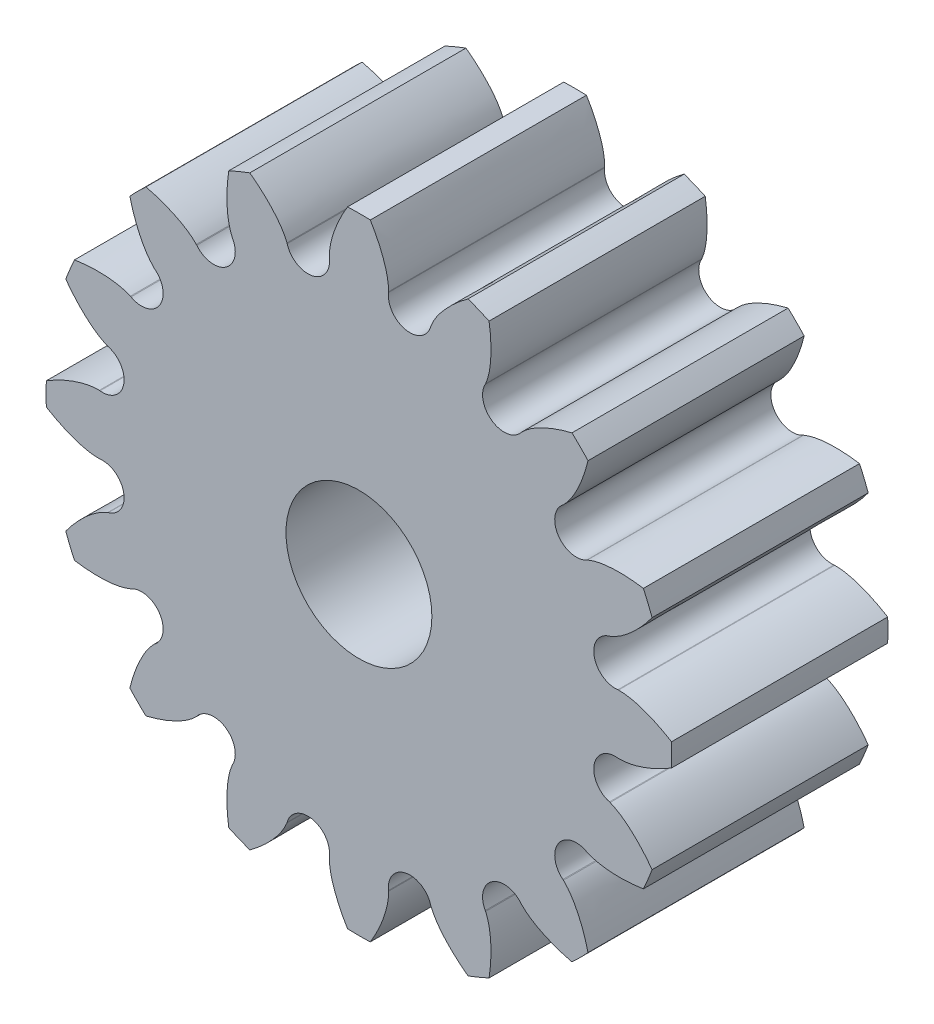
from build123d import *

# Parameters (mm, degrees)
SKETCH3_R                      = 3.3401
SKETCH3_R_2                    = 1.016
BASE_DEPTH                     = 3.0099
HALF_TOOTH_DEPTH               = 3.0099
PATTERN_OF_TOOTH_COUNT         = 16
PATTERN_OF_TOOTH_COPY_1_DEPTH  = 3.0099
PATTERN_OF_TOOTH_COPY_2_DEPTH  = 3.0099
PATTERN_OF_TOOTH_COPY_3_DEPTH  = 3.0099
PATTERN_OF_TOOTH_COPY_4_DEPTH  = 3.0099
PATTERN_OF_TOOTH_COPY_5_DEPTH  = 3.0099
PATTERN_OF_TOOTH_COPY_6_DEPTH  = 3.0099
PATTERN_OF_TOOTH_COPY_7_DEPTH  = 3.0099
PATTERN_OF_TOOTH_COPY_8_DEPTH  = 3.0099
PATTERN_OF_TOOTH_COPY_9_DEPTH  = 3.0099
PATTERN_OF_TOOTH_COPY_10_DEPTH = 3.0099
PATTERN_OF_TOOTH_COPY_11_DEPTH = 3.0099
PATTERN_OF_TOOTH_COPY_12_DEPTH = 3.0099
PATTERN_OF_TOOTH_COPY_13_DEPTH = 3.0099
PATTERN_OF_TOOTH_COPY_14_DEPTH = 3.0099
PATTERN_OF_TOOTH_COPY_15_DEPTH = 3.0099


with BuildPart() as part:
    # Sketch3 → Base (new body)
    with BuildSketch(Plane.XY):
        Circle(SKETCH3_R)
        Circle(SKETCH3_R_2, mode=Mode.SUBTRACT)
    extrude(amount=BASE_DEPTH)

    # Sketch2 → Half tooth (add)
    with BuildSketch(Plane.XY):
        with BuildLine():
            Line((0, 4.3561), (0, 3.3401))
            ThreePointArc((0, 3.3401), (0.32738705, 3.324016506), (0.651621185, 3.275920915))
            ThreePointArc((0.651621185, 3.275920915), (0.467325041, 3.393625885), (0.411449549, 3.605043618))
            Line((0.411449549, 3.605043618), (0.412597791, 3.615104304))
            add(Edge.make_bspline(
                [(0.158354022, 4.353220786), (0.239658153, 4.219695841), (0.355568747, 3.981504855), (0.41384102, 3.72189163), (0.412597791, 3.615104304)],
                knots=[0, 0, 0, 0, 0.595051021, 1, 1, 1, 1], degree=3))
            ThreePointArc((0.158354022, 4.353220786), (0.079190098, 4.355380137), (0, 4.3561))
        make_face()
    half_tooth = extrude(amount=HALF_TOOTH_DEPTH)

    # Mirror of half tooth: Half tooth across plane
    add(half_tooth.mirror(Plane.ZY))

    # Pattern of tooth: Half tooth ×16 about axis
    pattern_of_tooth_axis = Axis((0, 0, 3.0099), (0, 0, 1))
    for i in range(1, PATTERN_OF_TOOTH_COUNT):
        add(half_tooth.rotate(pattern_of_tooth_axis, i * 360 / PATTERN_OF_TOOTH_COUNT))

    # Pattern of tooth copy 1 sketch → Pattern of tooth copy 1 (add)
    with BuildSketch(Plane(origin=(0, 0, 0), x_dir=(-0.923879533, -0.382683432, 0), z_dir=(0, 0, 1))):
        with BuildLine():
            Line((0, -4.3561), (0, -3.3401))
            ThreePointArc((0, -3.3401), (0.32738705, -3.324016506), (0.651621185, -3.275920915))
            ThreePointArc((0.651621185, -3.275920915), (0.467325041, -3.393625885), (0.411449549, -3.605043618))
            Line((0.411449549, -3.605043618), (0.412597791, -3.615104304))
            add(Edge.make_bspline(
                [(0.158354022, -4.353220786), (0.239658153, -4.219695841), (0.355568747, -3.981504855), (0.41384102, -3.72189163), (0.412597791, -3.615104304)],
                knots=[0, 0, 0, 0, 0.595051021, 1, 1, 1, 1], degree=3))
            ThreePointArc((0.158354022, -4.353220786), (0.079190098, -4.355380137), (0, -4.3561))
        make_face()
    extrude(amount=PATTERN_OF_TOOTH_COPY_1_DEPTH)

    # Pattern of tooth copy 2 sketch → Pattern of tooth copy 2 (add)
    with BuildSketch(Plane(origin=(0, 0, 0), x_dir=(-0.707106781, -0.707106781, 0), z_dir=(0, 0, 1))):
        with BuildLine():
            Line((0, -4.3561), (0, -3.3401))
            ThreePointArc((0, -3.3401), (0.32738705, -3.324016506), (0.651621185, -3.275920915))
            ThreePointArc((0.651621185, -3.275920915), (0.467325041, -3.393625885), (0.411449549, -3.605043618))
            Line((0.411449549, -3.605043618), (0.412597791, -3.615104304))
            add(Edge.make_bspline(
                [(0.158354022, -4.353220786), (0.239658153, -4.219695841), (0.355568747, -3.981504855), (0.41384102, -3.72189163), (0.412597791, -3.615104304)],
                knots=[0, 0, 0, 0, 0.595051021, 1, 1, 1, 1], degree=3))
            ThreePointArc((0.158354022, -4.353220786), (0.079190098, -4.355380137), (0, -4.3561))
        make_face()
    extrude(amount=PATTERN_OF_TOOTH_COPY_2_DEPTH)

    # Pattern of tooth copy 3 sketch → Pattern of tooth copy 3 (add)
    with BuildSketch(Plane(origin=(0, 0, 0), x_dir=(-0.382683432, -0.923879533, 0), z_dir=(0, 0, 1))):
        with BuildLine():
            Line((0, -4.3561), (0, -3.3401))
            ThreePointArc((0, -3.3401), (0.32738705, -3.324016506), (0.651621185, -3.275920915))
            ThreePointArc((0.651621185, -3.275920915), (0.467325041, -3.393625885), (0.411449549, -3.605043618))
            Line((0.411449549, -3.605043618), (0.412597791, -3.615104304))
            add(Edge.make_bspline(
                [(0.158354022, -4.353220786), (0.239658153, -4.219695841), (0.355568747, -3.981504855), (0.41384102, -3.72189163), (0.412597791, -3.615104304)],
                knots=[0, 0, 0, 0, 0.595051021, 1, 1, 1, 1], degree=3))
            ThreePointArc((0.158354022, -4.353220786), (0.079190098, -4.355380137), (0, -4.3561))
        make_face()
    extrude(amount=PATTERN_OF_TOOTH_COPY_3_DEPTH)

    # Pattern of tooth copy 4 sketch → Pattern of tooth copy 4 (add)
    with BuildSketch(Plane(origin=(0, 0, 0), x_dir=(0, -1, 0), z_dir=(0, 0, 1))):
        with BuildLine():
            Line((0, -4.3561), (0, -3.3401))
            ThreePointArc((0, -3.3401), (0.32738705, -3.324016506), (0.651621185, -3.275920915))
            ThreePointArc((0.651621185, -3.275920915), (0.467325041, -3.393625885), (0.411449549, -3.605043618))
            Line((0.411449549, -3.605043618), (0.412597791, -3.615104304))
            add(Edge.make_bspline(
                [(0.158354022, -4.353220786), (0.239658153, -4.219695841), (0.355568747, -3.981504855), (0.41384102, -3.72189163), (0.412597791, -3.615104304)],
                knots=[0, 0, 0, 0, 0.595051021, 1, 1, 1, 1], degree=3))
            ThreePointArc((0.158354022, -4.353220786), (0.079190098, -4.355380137), (0, -4.3561))
        make_face()
    extrude(amount=PATTERN_OF_TOOTH_COPY_4_DEPTH)

    # Pattern of tooth copy 5 sketch → Pattern of tooth copy 5 (add)
    with BuildSketch(Plane(origin=(0, 0, 0), x_dir=(0.382683432, -0.923879533, 0), z_dir=(0, 0, 1))):
        with BuildLine():
            Line((0, -4.3561), (0, -3.3401))
            ThreePointArc((0, -3.3401), (0.32738705, -3.324016506), (0.651621185, -3.275920915))
            ThreePointArc((0.651621185, -3.275920915), (0.467325041, -3.393625885), (0.411449549, -3.605043618))
            Line((0.411449549, -3.605043618), (0.412597791, -3.615104304))
            add(Edge.make_bspline(
                [(0.158354022, -4.353220786), (0.239658153, -4.219695841), (0.355568747, -3.981504855), (0.41384102, -3.72189163), (0.412597791, -3.615104304)],
                knots=[0, 0, 0, 0, 0.595051021, 1, 1, 1, 1], degree=3))
            ThreePointArc((0.158354022, -4.353220786), (0.079190098, -4.355380137), (0, -4.3561))
        make_face()
    extrude(amount=PATTERN_OF_TOOTH_COPY_5_DEPTH)

    # Pattern of tooth copy 6 sketch → Pattern of tooth copy 6 (add)
    with BuildSketch(Plane(origin=(0, 0, 0), x_dir=(0.707106781, -0.707106781, 0), z_dir=(0, 0, 1))):
        with BuildLine():
            Line((0, -4.3561), (0, -3.3401))
            ThreePointArc((0, -3.3401), (0.32738705, -3.324016506), (0.651621185, -3.275920915))
            ThreePointArc((0.651621185, -3.275920915), (0.467325041, -3.393625885), (0.411449549, -3.605043618))
            Line((0.411449549, -3.605043618), (0.412597791, -3.615104304))
            add(Edge.make_bspline(
                [(0.158354022, -4.353220786), (0.239658153, -4.219695841), (0.355568747, -3.981504855), (0.41384102, -3.72189163), (0.412597791, -3.615104304)],
                knots=[0, 0, 0, 0, 0.595051021, 1, 1, 1, 1], degree=3))
            ThreePointArc((0.158354022, -4.353220786), (0.079190098, -4.355380137), (0, -4.3561))
        make_face()
    extrude(amount=PATTERN_OF_TOOTH_COPY_6_DEPTH)

    # Pattern of tooth copy 7 sketch → Pattern of tooth copy 7 (add)
    with BuildSketch(Plane(origin=(0, 0, 0), x_dir=(0.923879533, -0.382683432, 0), z_dir=(0, 0, 1))):
        with BuildLine():
            Line((0, -4.3561), (0, -3.3401))
            ThreePointArc((0, -3.3401), (0.32738705, -3.324016506), (0.651621185, -3.275920915))
            ThreePointArc((0.651621185, -3.275920915), (0.467325041, -3.393625885), (0.411449549, -3.605043618))
            Line((0.411449549, -3.605043618), (0.412597791, -3.615104304))
            add(Edge.make_bspline(
                [(0.158354022, -4.353220786), (0.239658153, -4.219695841), (0.355568747, -3.981504855), (0.41384102, -3.72189163), (0.412597791, -3.615104304)],
                knots=[0, 0, 0, 0, 0.595051021, 1, 1, 1, 1], degree=3))
            ThreePointArc((0.158354022, -4.353220786), (0.079190098, -4.355380137), (0, -4.3561))
        make_face()
    extrude(amount=PATTERN_OF_TOOTH_COPY_7_DEPTH)

    # Pattern of tooth copy 8 sketch → Pattern of tooth copy 8 (add)
    with BuildSketch(Plane.XY):
        with BuildLine():
            Line((0, -4.3561), (0, -3.3401))
            ThreePointArc((0, -3.3401), (0.32738705, -3.324016506), (0.651621185, -3.275920915))
            ThreePointArc((0.651621185, -3.275920915), (0.467325041, -3.393625885), (0.411449549, -3.605043618))
            Line((0.411449549, -3.605043618), (0.412597791, -3.615104304))
            add(Edge.make_bspline(
                [(0.158354022, -4.353220786), (0.239658153, -4.219695841), (0.355568747, -3.981504855), (0.41384102, -3.72189163), (0.412597791, -3.615104304)],
                knots=[0, 0, 0, 0, 0.595051021, 1, 1, 1, 1], degree=3))
            ThreePointArc((0.158354022, -4.353220786), (0.079190098, -4.355380137), (0, -4.3561))
        make_face()
    extrude(amount=PATTERN_OF_TOOTH_COPY_8_DEPTH)

    # Pattern of tooth copy 9 sketch → Pattern of tooth copy 9 (add)
    with BuildSketch(Plane(origin=(0, 0, 0), x_dir=(0.923879533, 0.382683432, 0), z_dir=(0, 0, 1))):
        with BuildLine():
            Line((0, -4.3561), (0, -3.3401))
            ThreePointArc((0, -3.3401), (0.32738705, -3.324016506), (0.651621185, -3.275920915))
            ThreePointArc((0.651621185, -3.275920915), (0.467325041, -3.393625885), (0.411449549, -3.605043618))
            Line((0.411449549, -3.605043618), (0.412597791, -3.615104304))
            add(Edge.make_bspline(
                [(0.158354022, -4.353220786), (0.239658153, -4.219695841), (0.355568747, -3.981504855), (0.41384102, -3.72189163), (0.412597791, -3.615104304)],
                knots=[0, 0, 0, 0, 0.595051021, 1, 1, 1, 1], degree=3))
            ThreePointArc((0.158354022, -4.353220786), (0.079190098, -4.355380137), (0, -4.3561))
        make_face()
    extrude(amount=PATTERN_OF_TOOTH_COPY_9_DEPTH)

    # Pattern of tooth copy 10 sketch → Pattern of tooth copy 10 (add)
    with BuildSketch(Plane(origin=(0, 0, 0), x_dir=(0.707106781, 0.707106781, 0), z_dir=(0, 0, 1))):
        with BuildLine():
            Line((0, -4.3561), (0, -3.3401))
            ThreePointArc((0, -3.3401), (0.32738705, -3.324016506), (0.651621185, -3.275920915))
            ThreePointArc((0.651621185, -3.275920915), (0.467325041, -3.393625885), (0.411449549, -3.605043618))
            Line((0.411449549, -3.605043618), (0.412597791, -3.615104304))
            add(Edge.make_bspline(
                [(0.158354022, -4.353220786), (0.239658153, -4.219695841), (0.355568747, -3.981504855), (0.41384102, -3.72189163), (0.412597791, -3.615104304)],
                knots=[0, 0, 0, 0, 0.595051021, 1, 1, 1, 1], degree=3))
            ThreePointArc((0.158354022, -4.353220786), (0.079190098, -4.355380137), (0, -4.3561))
        make_face()
    extrude(amount=PATTERN_OF_TOOTH_COPY_10_DEPTH)

    # Pattern of tooth copy 11 sketch → Pattern of tooth copy 11 (add)
    with BuildSketch(Plane(origin=(0, 0, 0), x_dir=(0.382683432, 0.923879533, 0), z_dir=(0, 0, 1))):
        with BuildLine():
            Line((0, -4.3561), (0, -3.3401))
            ThreePointArc((0, -3.3401), (0.32738705, -3.324016506), (0.651621185, -3.275920915))
            ThreePointArc((0.651621185, -3.275920915), (0.467325041, -3.393625885), (0.411449549, -3.605043618))
            Line((0.411449549, -3.605043618), (0.412597791, -3.615104304))
            add(Edge.make_bspline(
                [(0.158354022, -4.353220786), (0.239658153, -4.219695841), (0.355568747, -3.981504855), (0.41384102, -3.72189163), (0.412597791, -3.615104304)],
                knots=[0, 0, 0, 0, 0.595051021, 1, 1, 1, 1], degree=3))
            ThreePointArc((0.158354022, -4.353220786), (0.079190098, -4.355380137), (0, -4.3561))
        make_face()
    extrude(amount=PATTERN_OF_TOOTH_COPY_11_DEPTH)

    # Pattern of tooth copy 12 sketch → Pattern of tooth copy 12 (add)
    with BuildSketch(Plane(origin=(0, 0, 0), x_dir=(0, 1, 0), z_dir=(0, 0, 1))):
        with BuildLine():
            Line((0, -4.3561), (0, -3.3401))
            ThreePointArc((0, -3.3401), (0.32738705, -3.324016506), (0.651621185, -3.275920915))
            ThreePointArc((0.651621185, -3.275920915), (0.467325041, -3.393625885), (0.411449549, -3.605043618))
            Line((0.411449549, -3.605043618), (0.412597791, -3.615104304))
            add(Edge.make_bspline(
                [(0.158354022, -4.353220786), (0.239658153, -4.219695841), (0.355568747, -3.981504855), (0.41384102, -3.72189163), (0.412597791, -3.615104304)],
                knots=[0, 0, 0, 0, 0.595051021, 1, 1, 1, 1], degree=3))
            ThreePointArc((0.158354022, -4.353220786), (0.079190098, -4.355380137), (0, -4.3561))
        make_face()
    extrude(amount=PATTERN_OF_TOOTH_COPY_12_DEPTH)

    # Pattern of tooth copy 13 sketch → Pattern of tooth copy 13 (add)
    with BuildSketch(Plane(origin=(0, 0, 0), x_dir=(-0.382683432, 0.923879533, 0), z_dir=(0, 0, 1))):
        with BuildLine():
            Line((0, -4.3561), (0, -3.3401))
            ThreePointArc((0, -3.3401), (0.32738705, -3.324016506), (0.651621185, -3.275920915))
            ThreePointArc((0.651621185, -3.275920915), (0.467325041, -3.393625885), (0.411449549, -3.605043618))
            Line((0.411449549, -3.605043618), (0.412597791, -3.615104304))
            add(Edge.make_bspline(
                [(0.158354022, -4.353220786), (0.239658153, -4.219695841), (0.355568747, -3.981504855), (0.41384102, -3.72189163), (0.412597791, -3.615104304)],
                knots=[0, 0, 0, 0, 0.595051021, 1, 1, 1, 1], degree=3))
            ThreePointArc((0.158354022, -4.353220786), (0.079190098, -4.355380137), (0, -4.3561))
        make_face()
    extrude(amount=PATTERN_OF_TOOTH_COPY_13_DEPTH)

    # Pattern of tooth copy 14 sketch → Pattern of tooth copy 14 (add)
    with BuildSketch(Plane(origin=(0, 0, 0), x_dir=(-0.707106781, 0.707106781, 0), z_dir=(0, 0, 1))):
        with BuildLine():
            Line((0, -4.3561), (0, -3.3401))
            ThreePointArc((0, -3.3401), (0.32738705, -3.324016506), (0.651621185, -3.275920915))
            ThreePointArc((0.651621185, -3.275920915), (0.467325041, -3.393625885), (0.411449549, -3.605043618))
            Line((0.411449549, -3.605043618), (0.412597791, -3.615104304))
            add(Edge.make_bspline(
                [(0.158354022, -4.353220786), (0.239658153, -4.219695841), (0.355568747, -3.981504855), (0.41384102, -3.72189163), (0.412597791, -3.615104304)],
                knots=[0, 0, 0, 0, 0.595051021, 1, 1, 1, 1], degree=3))
            ThreePointArc((0.158354022, -4.353220786), (0.079190098, -4.355380137), (0, -4.3561))
        make_face()
    extrude(amount=PATTERN_OF_TOOTH_COPY_14_DEPTH)

    # Pattern of tooth copy 15 sketch → Pattern of tooth copy 15 (add)
    with BuildSketch(Plane(origin=(0, 0, 0), x_dir=(-0.923879533, 0.382683432, 0), z_dir=(0, 0, 1))):
        with BuildLine():
            Line((0, -4.3561), (0, -3.3401))
            ThreePointArc((0, -3.3401), (0.32738705, -3.324016506), (0.651621185, -3.275920915))
            ThreePointArc((0.651621185, -3.275920915), (0.467325041, -3.393625885), (0.411449549, -3.605043618))
            Line((0.411449549, -3.605043618), (0.412597791, -3.615104304))
            add(Edge.make_bspline(
                [(0.158354022, -4.353220786), (0.239658153, -4.219695841), (0.355568747, -3.981504855), (0.41384102, -3.72189163), (0.412597791, -3.615104304)],
                knots=[0, 0, 0, 0, 0.595051021, 1, 1, 1, 1], degree=3))
            ThreePointArc((0.158354022, -4.353220786), (0.079190098, -4.355380137), (0, -4.3561))
        make_face()
    extrude(amount=PATTERN_OF_TOOTH_COPY_15_DEPTH)


solid = part.part
